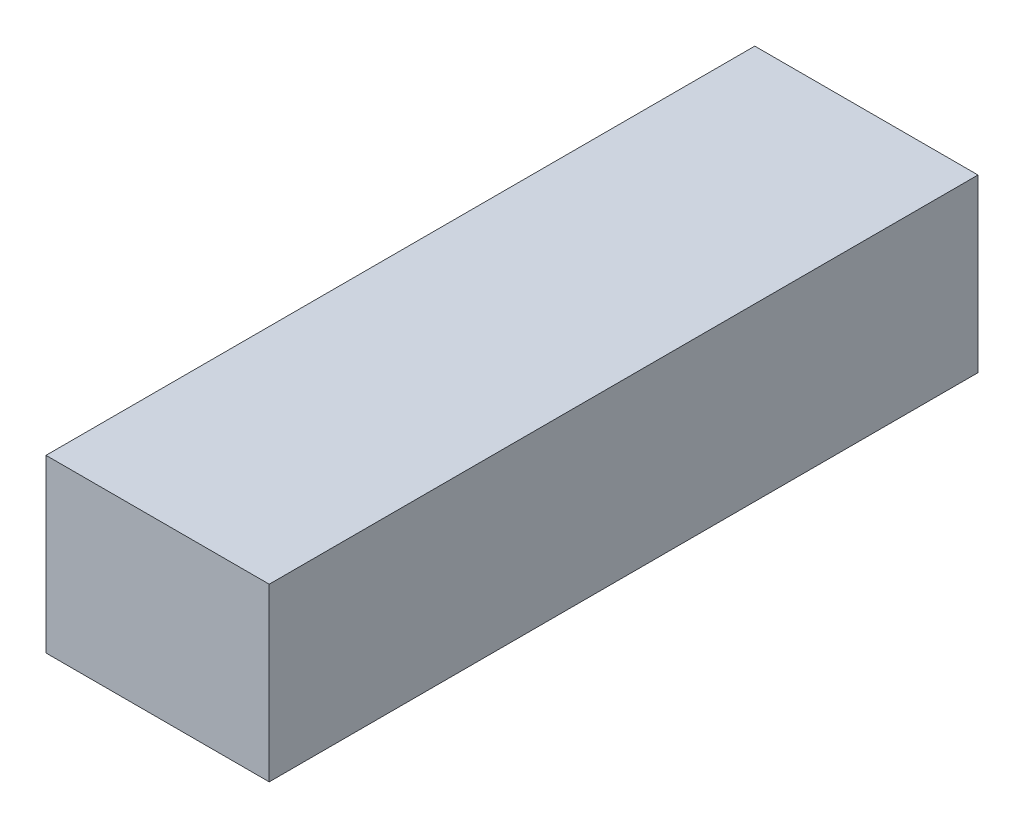
from build123d import *

# Parameters (mm, degrees)
SKETCH1_W           = 48.5
SKETCH1_H           = 37.2
BOSS_EXTRUDE1_DEPTH = 154


with BuildPart() as part:
    # Sketch1 → Boss-Extrude1 (new body)
    with BuildSketch(Plane.XY):
        Rectangle(SKETCH1_W, SKETCH1_H)
    extrude(amount=BOSS_EXTRUDE1_DEPTH)


solid = part.part
